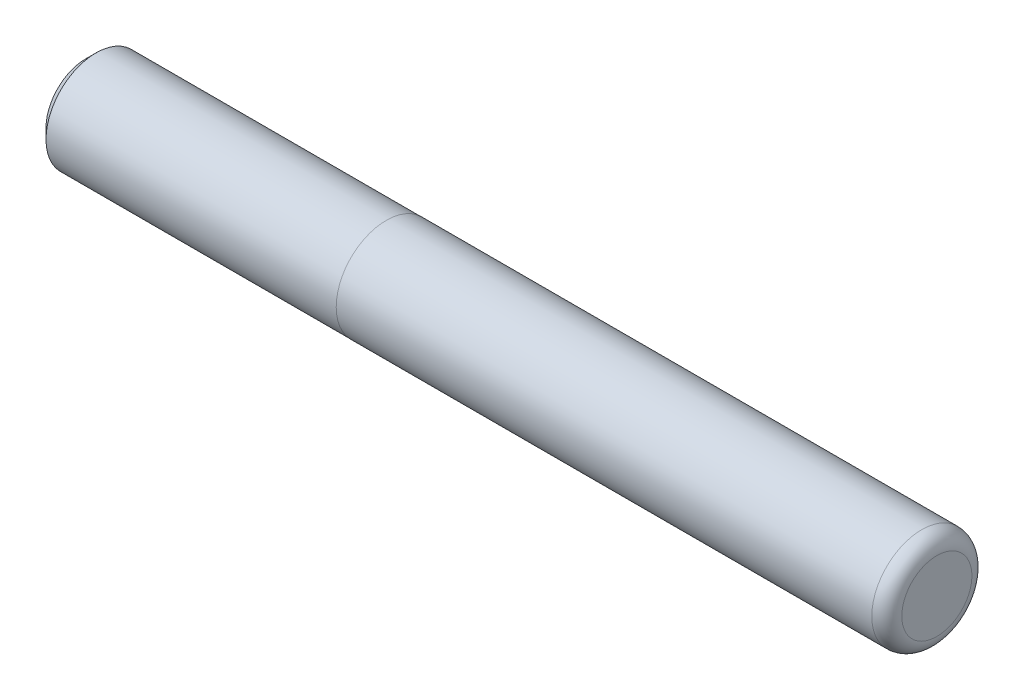
from build123d import *


with BuildPart() as part:
    # Esquisse1 → Révolution1 (revolve)
    with BuildSketch(Plane.XY):
        with BuildLine():
            Line((0, 0), (0, 3.5))
            ThreePointArc((0, 3.5), (-0.439339828, 4.560660172), (-1.5, 5))
            Line((-1.5, 5), (-55, 5))
            Line((-55, 5), (-55, 4.99))
            Line((-55, 4.99), (-84, 4.99))
            Line((-84, 4.99), (-85, 3.99))
            Line((-85, 3.99), (-85, 0))
            Line((-85, 0), (0, 0))
        make_face()
    revolve(axis=Axis((-85, 0, 0), (1, 0, 0)))


solid = part.part
